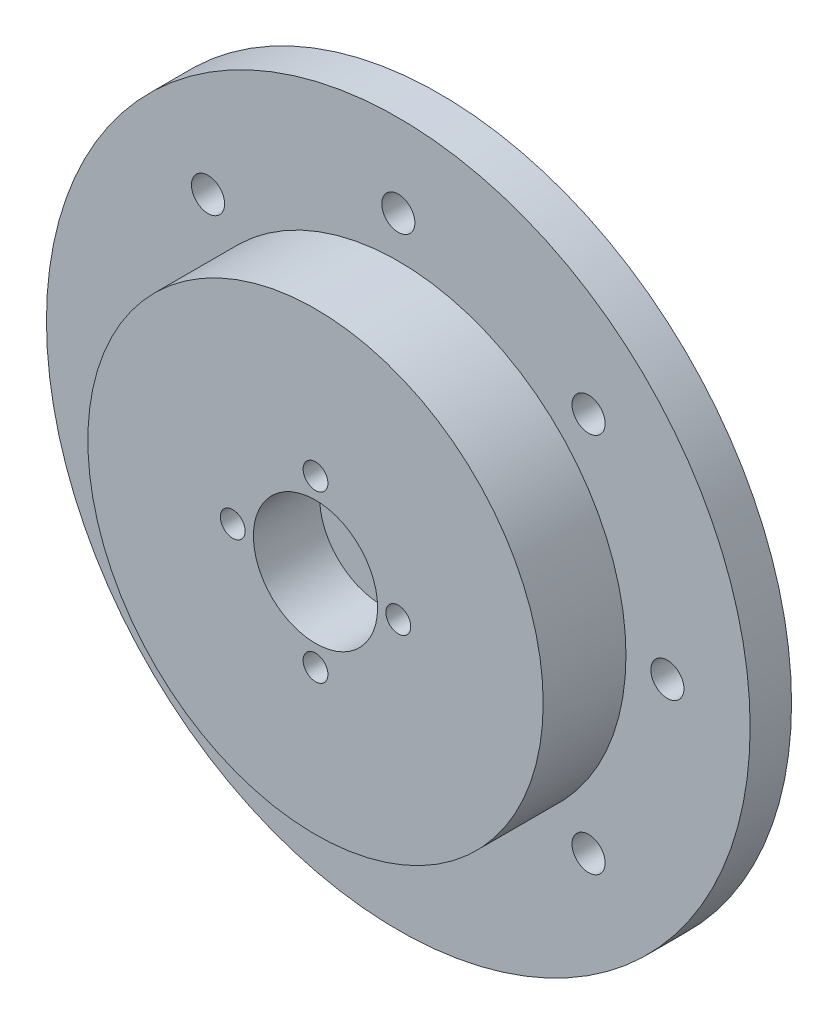
from build123d import *

# Parameters (mm, degrees)
SKETCH1_R           = 42.5
BOSS_EXTRUDE1_DEPTH = 5
SKETCH2_R           = 27.5
BOSS_EXTRUDE2_DEPTH = 10
SKETCH3_R           = 7.5
CUT_EXTRUDE1_DEPTH  = 8
SKETCH4_R           = 1.5
CUT_EXTRUDE2_DEPTH  = 16
SKETCH5_R           = 2
CUT_EXTRUDE3_DEPTH  = 6


with BuildPart() as part:
    # Sketch1 → Boss-Extrude1 (new body)
    with BuildSketch(Plane.XY):
        Circle(SKETCH1_R)
    extrude(amount=BOSS_EXTRUDE1_DEPTH)

    # Sketch2 → Boss-Extrude2 (add)
    with BuildSketch(Plane.XY.offset(5)):
        Circle(SKETCH2_R)
    extrude(amount=BOSS_EXTRUDE2_DEPTH)

    # Sketch3 → Cut-Extrude1 (cut)
    with BuildSketch(Plane.XY.offset(15)):
        Circle(SKETCH3_R)
    extrude(amount=-CUT_EXTRUDE1_DEPTH, mode=Mode.SUBTRACT)

    # Sketch4 → Cut-Extrude2 (cut, through all)
    with BuildSketch(Plane.XY.offset(15)):
        with Locations((0, 10)):
            Circle(SKETCH4_R)
        with Locations((10, 0)):
            Circle(SKETCH4_R)
        with Locations((0, -10)):
            Circle(SKETCH4_R)
        with Locations((-10, 0)):
            Circle(SKETCH4_R)
    extrude(amount=-CUT_EXTRUDE2_DEPTH, mode=Mode.SUBTRACT)

    # Sketch5 → Cut-Extrude3 (cut, through all)
    with BuildSketch(Plane.XY.offset(5)):
        with Locations((0, 32.5)):
            Circle(SKETCH5_R)
        with Locations((22.980970389, 22.980970389)):
            Circle(SKETCH5_R)
        with Locations((32.5, 0)):
            Circle(SKETCH5_R)
        with Locations((22.980970389, -22.980970389)):
            Circle(SKETCH5_R)
        with Locations((0, -32.5)):
            Circle(SKETCH5_R)
        with Locations((-22.980970389, -22.980970389)):
            Circle(SKETCH5_R)
        with Locations((-32.5, 0)):
            Circle(SKETCH5_R)
        with Locations((-22.980970389, 22.980970389)):
            Circle(SKETCH5_R)
    extrude(amount=-CUT_EXTRUDE3_DEPTH, mode=Mode.SUBTRACT)


solid = part.part
